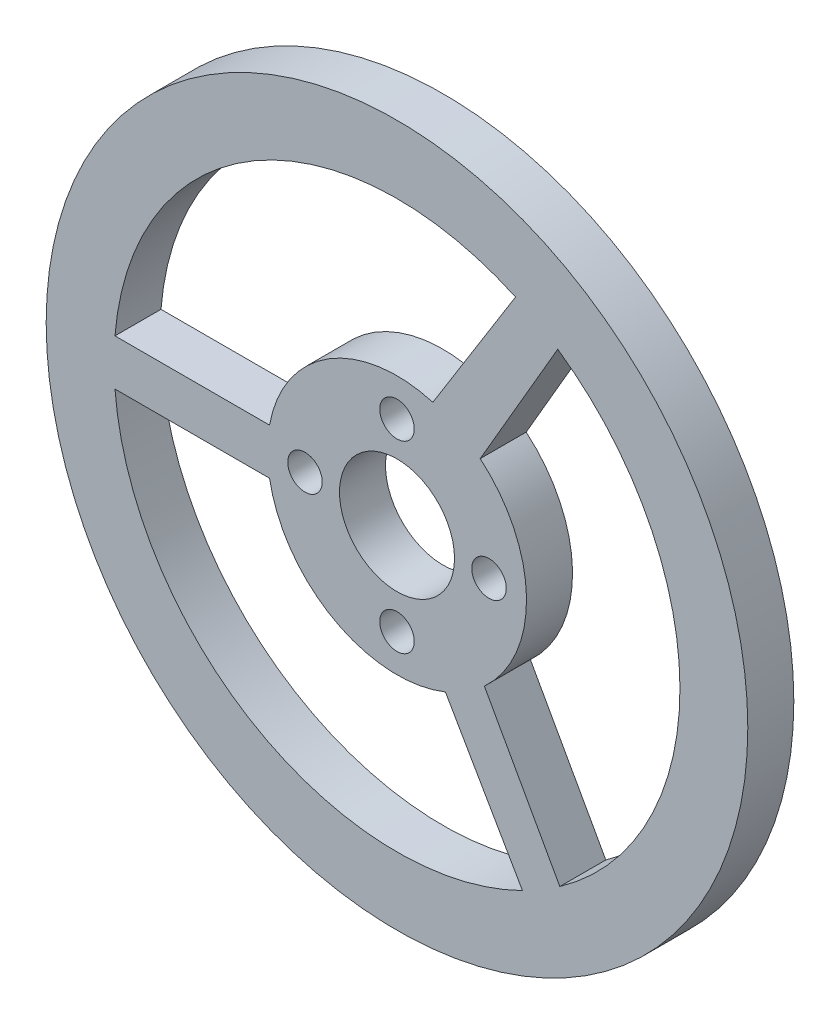
from build123d import *

# Parameters (mm, degrees)
SKETCH_1_R          = 30.5
EXTRUDE_1_DEPTH     = 4
CUT_EXTRUDE_1_REACH = 6
SKETCH_2_R          = 5
SKETCH_2_R_2        = 1.5


with BuildPart() as part:
    # 草图1 → 凸台-拉伸1 (new body)
    with BuildSketch(Plane.XY):
        Circle(SKETCH_1_R)
    extrude(amount=EXTRUDE_1_DEPTH)

    # 草图2 → 切除-拉伸1 (cut, up to next)
    with BuildSketch(Plane.XY.offset(4), mode=Mode.PRIVATE) as cut_extrude_1_sk1:
        Circle(SKETCH_2_R)
    cut_extrude_1_tool1 = extrude(cut_extrude_1_sk1.sketch, amount=-CUT_EXTRUDE_1_REACH, mode=Mode.PRIVATE) & part.part
    add(cut_extrude_1_tool1.solids().sort_by_distance((0, 0, 4))[0], mode=Mode.SUBTRACT)
    # 草图2 → 切除-拉伸1 (cut, up to next)
    with BuildSketch(Plane.XY.offset(4), mode=Mode.PRIVATE) as cut_extrude_1_sk2:
        with Locations((-8, 0)):
            Circle(SKETCH_2_R_2)
    cut_extrude_1_tool2 = extrude(cut_extrude_1_sk2.sketch, amount=-CUT_EXTRUDE_1_REACH, mode=Mode.PRIVATE) & part.part
    add(cut_extrude_1_tool2.solids().sort_by_distance((-8, 0, 4))[0], mode=Mode.SUBTRACT)
    # 草图2 → 切除-拉伸1 (cut, up to next)
    with BuildSketch(Plane.XY.offset(4), mode=Mode.PRIVATE) as cut_extrude_1_sk3:
        with Locations((0, 8)):
            Circle(SKETCH_2_R_2)
    cut_extrude_1_tool3 = extrude(cut_extrude_1_sk3.sketch, amount=-CUT_EXTRUDE_1_REACH, mode=Mode.PRIVATE) & part.part
    add(cut_extrude_1_tool3.solids().sort_by_distance((0, 8, 4))[0], mode=Mode.SUBTRACT)
    # 草图2 → 切除-拉伸1 (cut, up to next)
    with BuildSketch(Plane.XY.offset(4), mode=Mode.PRIVATE) as cut_extrude_1_sk4:
        with Locations((8, 0)):
            Circle(SKETCH_2_R_2)
    cut_extrude_1_tool4 = extrude(cut_extrude_1_sk4.sketch, amount=-CUT_EXTRUDE_1_REACH, mode=Mode.PRIVATE) & part.part
    add(cut_extrude_1_tool4.solids().sort_by_distance((8, 0, 4))[0], mode=Mode.SUBTRACT)
    # 草图2 → 切除-拉伸1 (cut, up to next)
    with BuildSketch(Plane.XY.offset(4), mode=Mode.PRIVATE) as cut_extrude_1_sk5:
        with Locations((0, -8)):
            Circle(SKETCH_2_R_2)
    cut_extrude_1_tool5 = extrude(cut_extrude_1_sk5.sketch, amount=-CUT_EXTRUDE_1_REACH, mode=Mode.PRIVATE) & part.part
    add(cut_extrude_1_tool5.solids().sort_by_distance((0, -8, 4))[0], mode=Mode.SUBTRACT)
    # 草图2 → 切除-拉伸1 (cut, up to next)
    with BuildSketch(Plane.XY.offset(4), mode=Mode.PRIVATE) as cut_extrude_1_sk6:
        with BuildLine():
            Line((-24.519245453, -2), (-11.082272055, -2))
            ThreePointArc((-11.082272055, -2), (-5.44406657, -9.857935539), (4.209531065, -10.444931887))
            Line((4.209531065, -10.444931887), (10.909403583, -22.049451491))
            ThreePointArc((10.909403583, -22.049451491), (-12.116190623, -21.410075254), (-24.519245453, -2))
        make_face()
    cut_extrude_1_tool6 = extrude(cut_extrude_1_sk6.sketch, amount=-CUT_EXTRUDE_1_REACH, mode=Mode.PRIVATE) & part.part
    add(cut_extrude_1_tool6.solids().sort_by_distance((-7.903429, -14.053546, 4))[0], mode=Mode.SUBTRACT)
    # 草图2 → 切除-拉伸1 (cut, up to next)
    with BuildSketch(Plane.XY.offset(4), mode=Mode.PRIVATE) as cut_extrude_1_sk7:
        with BuildLine():
            Line((-24.519245453, 2), (-11.082272055, 2))
            ThreePointArc((-11.082272055, 2), (-5.942459521, 9.565768592), (3.117477103, 10.821187108))
            Line((3.117477103, 10.821187108), (10.304921695, 22.338352367))
            ThreePointArc((10.304921695, 22.338352367), (-12.406606878, 21.243104843), (-24.519245453, 2))
        make_face()
    cut_extrude_1_tool7 = extrude(cut_extrude_1_sk7.sketch, amount=-CUT_EXTRUDE_1_REACH, mode=Mode.PRIVATE) & part.part
    add(cut_extrude_1_tool7.solids().sort_by_distance((-8.308104, 14.002241, 4))[0], mode=Mode.SUBTRACT)
    # 草图2 → 切除-拉伸1 (cut, up to next)
    with BuildSketch(Plane.XY.offset(4), mode=Mode.PRIVATE) as cut_extrude_1_sk8:
        with BuildLine():
            Line((14.155543142, -20.119989959), (7.597126799, -8.312666138))
            ThreePointArc((7.597126799, -8.312666138), (11.258684205, 0.242453893), (7.232225933, 8.632013784))
            Line((7.232225933, 8.632013784), (13.976038331, 20.245092002))
            ThreePointArc((13.976038331, 20.245092002), (24.600435555, 0.109398924), (14.155543142, -20.119989959))
        make_face()
    cut_extrude_1_tool8 = extrude(cut_extrude_1_sk8.sketch, amount=-CUT_EXTRUDE_1_REACH, mode=Mode.PRIVATE) & part.part
    add(cut_extrude_1_tool8.solids().sort_by_distance((16.242658, 0.143003, 4))[0], mode=Mode.SUBTRACT)


solid = part.part
